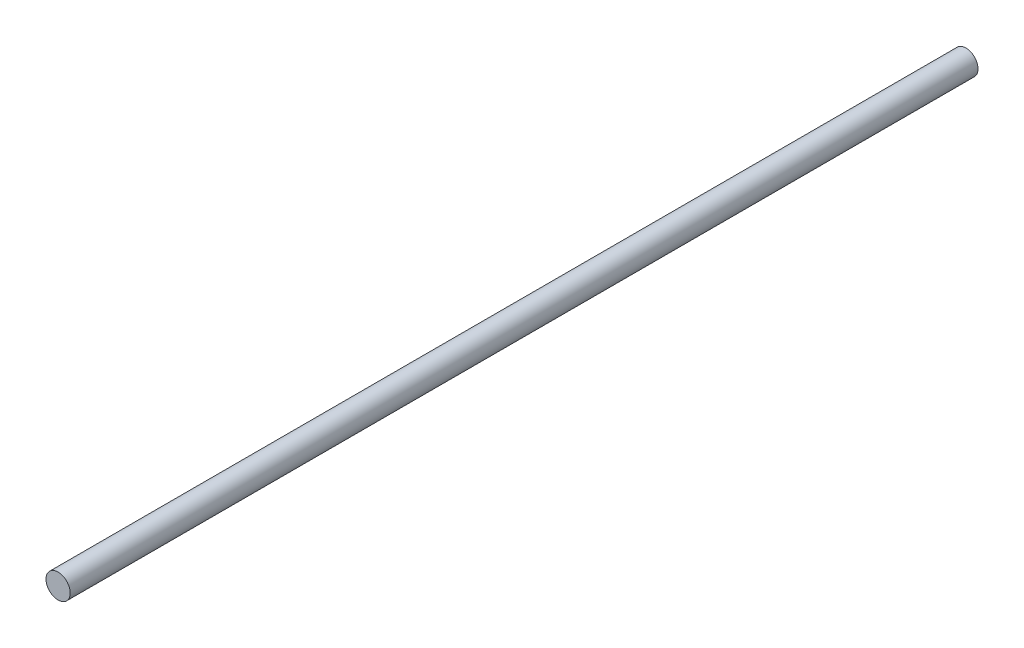
from build123d import *

# Parameters (mm, degrees)
SKETCH1_R           = 4
BOSS_EXTRUDE1_DEPTH = 300


with BuildPart() as part:
    # Sketch1 → Boss-Extrude1 (new body)
    with BuildSketch(Plane.XY):
        Circle(SKETCH1_R)
    extrude(amount=BOSS_EXTRUDE1_DEPTH)


solid = part.part
